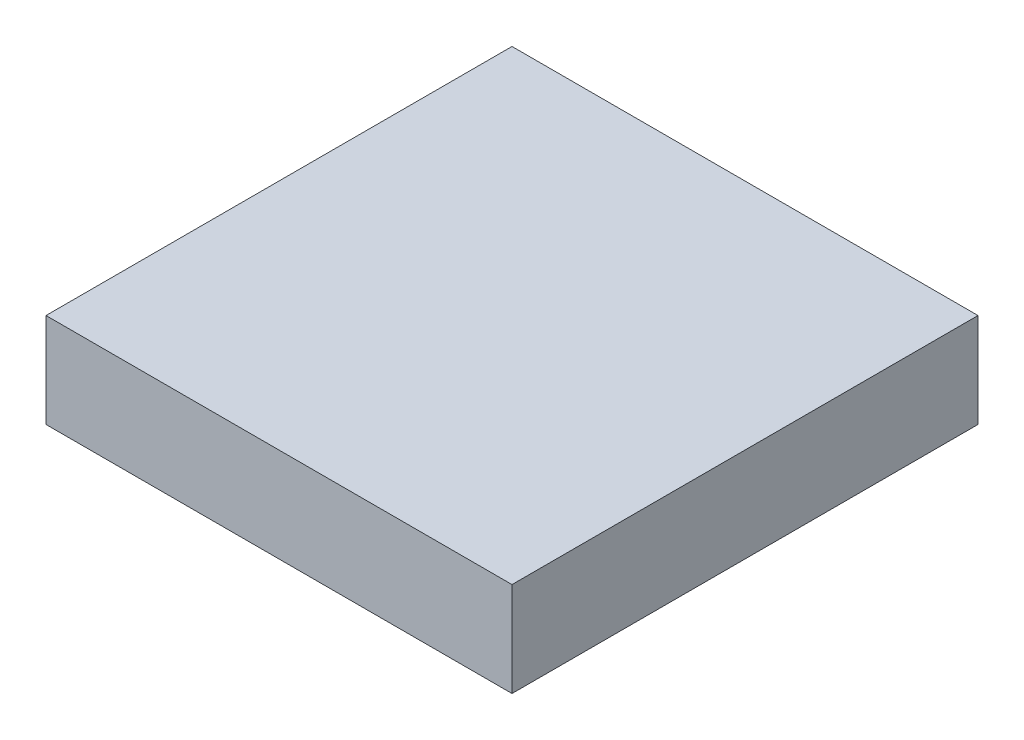
from build123d import *

# Parameters (mm, degrees)
SKETCH1_W          = 15.8
SKETCH1_H          = 15.8
BASE_DEPTH         = 3.2
SKETCH2_W          = 13.4
SKETCH2_H          = 13.4
SKETCH2_R          = 3.3
SKETCH2_R_2        = 2.5
CUT_EXTRUDE2_DEPTH = 2


with BuildPart() as part:
    # Sketch1 → Base (new body)
    with BuildSketch(Plane(origin=(0, 0, 0), x_dir=(1, 0, 0), z_dir=(0, 1, 0))):
        Rectangle(SKETCH1_W, SKETCH1_H)
    extrude(amount=BASE_DEPTH)

    # Sketch2 → Cut-Extrude2 (cut)
    with BuildSketch(Plane.XZ):
        Rectangle(SKETCH2_W, SKETCH2_H)
        Circle(SKETCH2_R, mode=Mode.SUBTRACT)
        Circle(SKETCH2_R_2)
    extrude(amount=-CUT_EXTRUDE2_DEPTH, mode=Mode.SUBTRACT)


solid = part.part
